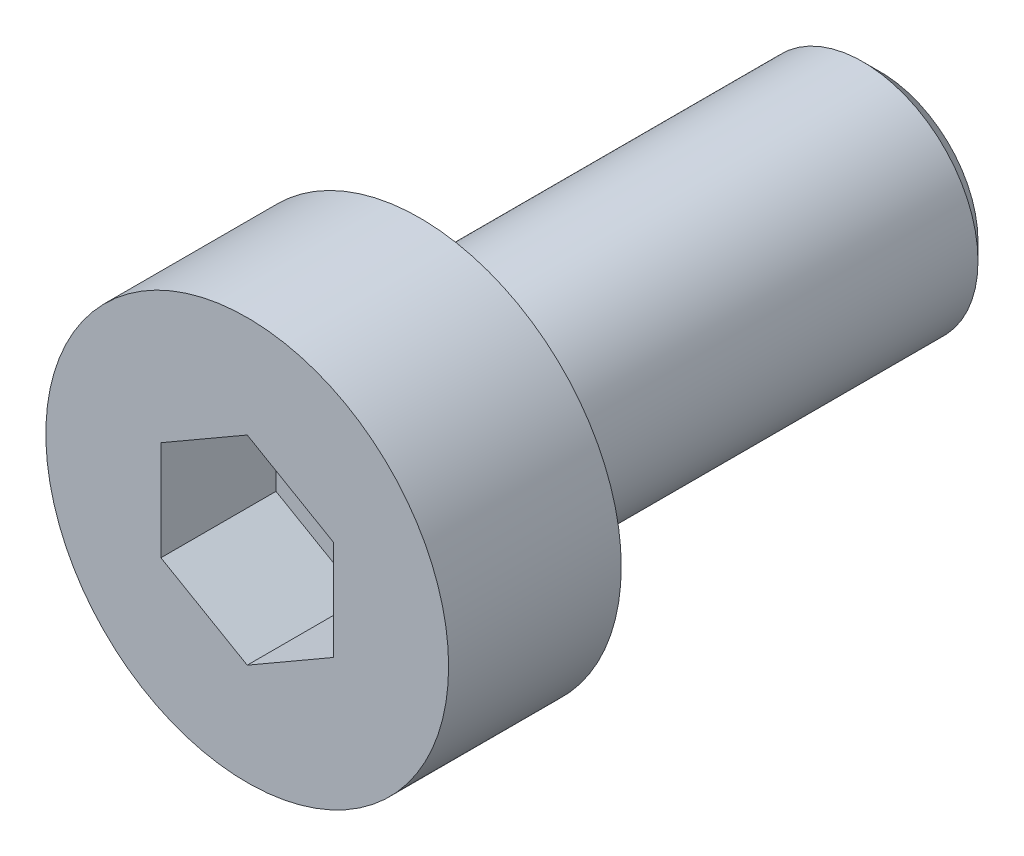
from build123d import *

# Parameters (mm, degrees)
SKETCH1_R           = 3.5
BOSS_EXTRUDE1_DEPTH = 3
SKETCH2_R           = 2
BOSS_EXTRUDE2_DEPTH = 8
CHAMFER1_SIZE       = 0.3
CUT_EXTRUDE1_DEPTH  = 2


with BuildPart() as part:
    # Sketch1 → Boss-Extrude1 (new body)
    with BuildSketch(Plane.XY):
        Circle(SKETCH1_R)
    extrude(amount=BOSS_EXTRUDE1_DEPTH)

    # Sketch2 → Boss-Extrude2 (add)
    with BuildSketch(Plane(origin=(0, 0, 0), x_dir=(-1, 0, 0), z_dir=(0, 0, -1))):
        Circle(SKETCH2_R)
    extrude(amount=BOSS_EXTRUDE2_DEPTH)

    # Chamfer1
    chamfer1_edges = [part.edges().sort_by_distance(p)[0] for p in [
        (2, 0, -8),
    ]]
    chamfer(chamfer1_edges, length=CHAMFER1_SIZE)

    # Sketch3 → Cut-Extrude1 (cut)
    with BuildSketch(Plane.XY.offset(3)):
        Polygon((0, 1.732050808), (-1.5, 0.866025404), (-1.5, -0.866025404), (0, -1.732050808), (1.5, -0.866025404), (1.5, 0.866025404), align=None)
    extrude(amount=-CUT_EXTRUDE1_DEPTH, mode=Mode.SUBTRACT)


solid = part.part
